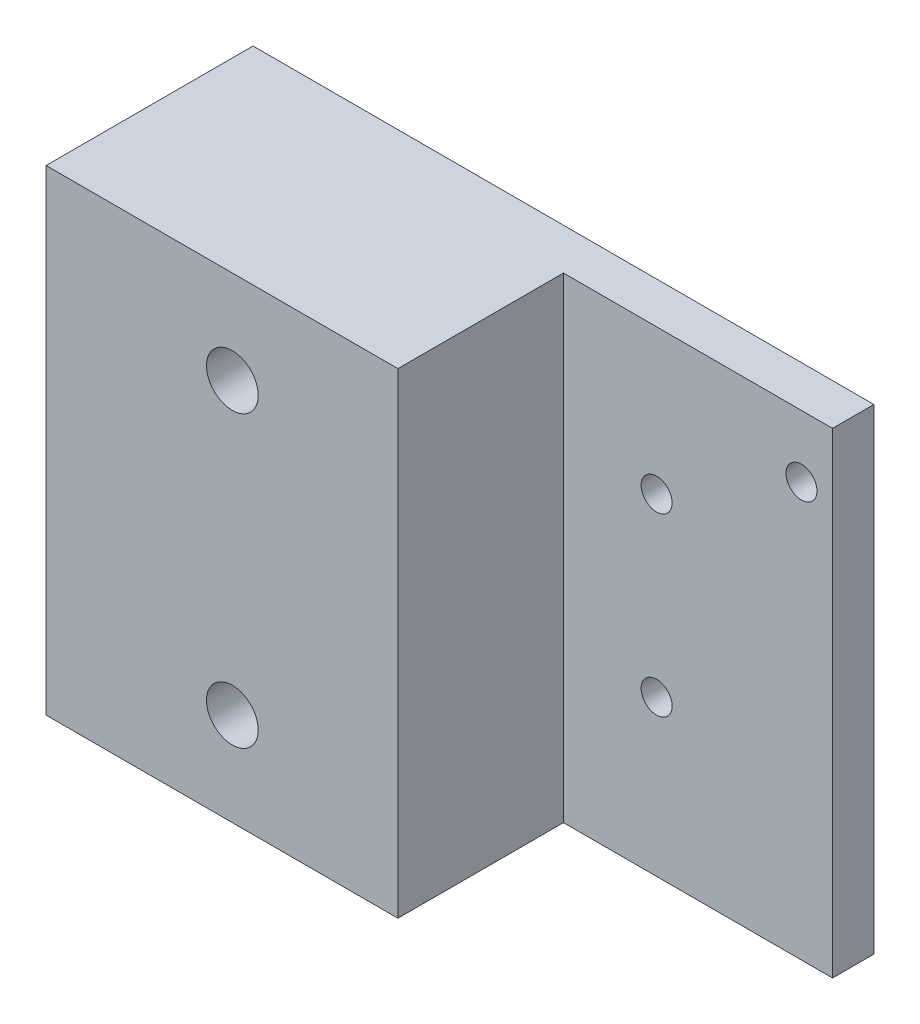
from build123d import *

# Parameters (mm, degrees)
ESBO_O1_W                = 60
ESBO_O1_H                = 46
RESSALTO_EXTRUS_O1_DEPTH = 20
ESBO_O2_W                = 26
ESBO_O2_H                = 46
CORTE_EXTRUS_O1_DEPTH    = 16
ESBO_O5_R                = 1.5
CORTE_EXTRUS_O3_DEPTH    = 5
ESBO_O8_R                = 2.5
CORTE_EXTRUS_O5_DEPTH    = 21
ESBO_O9_R                = 5
CORTE_EXTRUS_O6_DEPTH    = 7


with BuildPart() as part:
    # Esboço1 → Ressalto-extrusão1 (new body)
    with BuildSketch(Plane.XY):
        Rectangle(ESBO_O1_W, ESBO_O1_H)
    extrude(amount=RESSALTO_EXTRUS_O1_DEPTH)

    # Esboço2 → Corte-extrusão1 (cut)
    with BuildSketch(Plane.XY.offset(20)):
        with Locations((17, 0)):
            Rectangle(ESBO_O2_W, ESBO_O2_H)
    extrude(amount=-CORTE_EXTRUS_O1_DEPTH, mode=Mode.SUBTRACT)

    # Esboço5 → Corte-extrusão3 (cut, through all)
    with BuildSketch(Plane.XY.offset(4)):
        with Locations((13, 9)):
            Circle(ESBO_O5_R)
        with Locations((13, -8)):
            Circle(ESBO_O5_R)
        with Locations((27, 17)):
            Circle(ESBO_O5_R)
    extrude(amount=-CORTE_EXTRUS_O3_DEPTH, mode=Mode.SUBTRACT)

    # Esboço8 → Corte-extrusão5 (cut, through all)
    with BuildSketch(Plane.XY.offset(20)):
        with Locations((-12, -14)):
            Circle(ESBO_O8_R)
        with Locations((-12, 14)):
            Circle(ESBO_O8_R)
    extrude(amount=-CORTE_EXTRUS_O5_DEPTH, mode=Mode.SUBTRACT)

    # Esboço9 → Corte-extrusão6 (cut)
    with BuildSketch(Plane(origin=(0, 0, 0), x_dir=(-1, 0, 0), z_dir=(0, 0, -1))):
        with Locations((12, -14)):
            Circle(ESBO_O9_R)
        with Locations((12, 14.082568483)):
            Circle(ESBO_O9_R)
    extrude(amount=-CORTE_EXTRUS_O6_DEPTH, mode=Mode.SUBTRACT)


solid = part.part
